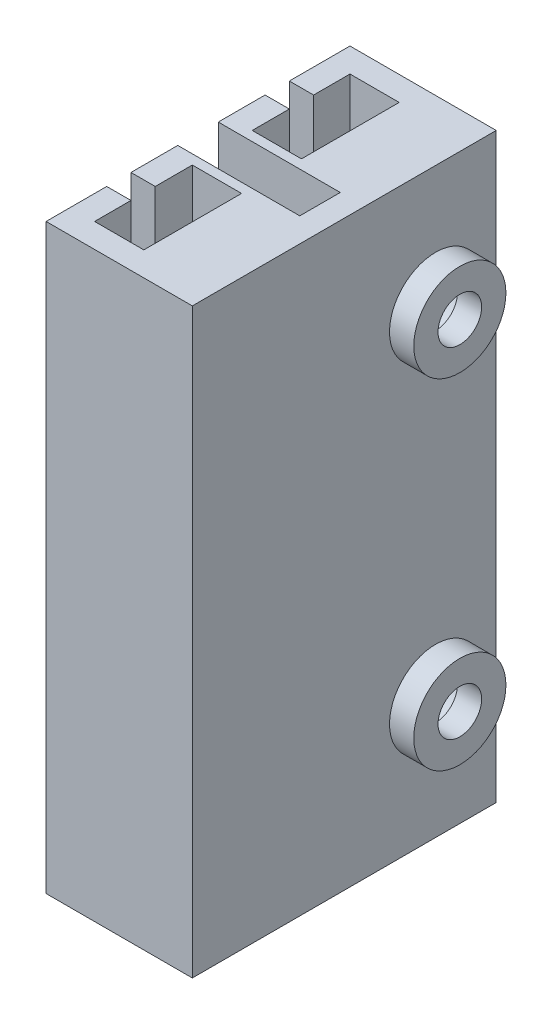
from build123d import *

# Parameters (mm, degrees)
SKETCH1_W           = 2.03
SKETCH1_H           = 4.03
BOSS_EXTRUDE1_DEPTH = 24
SKETCH2_W           = 1
SKETCH2_H           = 24
CUT_EXTRUDE1_DEPTH  = 2
SKETCH3_R           = 1.9
SKETCH3_R_2         = 0.9
BOSS_EXTRUDE2_DEPTH = 1
SKETCH4_R           = 1.15
CUT_EXTRUDE2_DEPTH  = 4


with BuildPart() as part:
    # Sketch1 → Boss-Extrude1 (new body)
    with BuildSketch(Plane(origin=(0, 0, 0), x_dir=(1, 0, 0), z_dir=(0, 1, 0))):
        Polygon((0.758759529, 5.315), (5, 5.315), (5, -7.215), (1.398203198, -7.215), (-1.03, -7.215), (-1.03, -1.785), (4, -1.785), (4, -0.115), (-1.03, -0.115), (-1.03, 5.315), align=None)
        with Locations((0.985, 2.3)):
            Rectangle(SKETCH1_W, SKETCH1_H, mode=Mode.SUBTRACT)
        with Locations((0.985, -4.2)):
            Rectangle(SKETCH1_W, SKETCH1_H, mode=Mode.SUBTRACT)
    extrude(amount=BOSS_EXTRUDE1_DEPTH)

    # Sketch2 → Cut-Extrude1 (cut)
    with BuildSketch(Plane.ZY.offset(1.03)):
        with Locations((-2.315, 12)):
            Rectangle(SKETCH2_W, SKETCH2_H)
        with Locations((4.215, 12)):
            Rectangle(SKETCH2_W, SKETCH2_H)
    extrude(amount=-CUT_EXTRUDE1_DEPTH, mode=Mode.SUBTRACT)

    # Sketch3 → Boss-Extrude2 (add)
    with BuildSketch(Plane(origin=(5, 0, 0), x_dir=(0, 0, -1), z_dir=(1, 0, 0))):
        with Locations((2.815, 19)):
            Circle(SKETCH3_R)
        with Locations((2.815, 19)):
            Circle(SKETCH3_R_2, mode=Mode.SUBTRACT)
        with Locations((2.815, 5)):
            Circle(SKETCH3_R)
        with Locations((2.815, 5)):
            Circle(SKETCH3_R_2, mode=Mode.SUBTRACT)
    extrude(amount=BOSS_EXTRUDE2_DEPTH)

    # Sketch4 → Cut-Extrude2 (cut)
    with BuildSketch(Plane(origin=(5, 0, 0), x_dir=(0, 0, -1), z_dir=(1, 0, 0))):
        with Locations((2.815, 19)):
            Circle(SKETCH4_R)
        with Locations((2.815, 5)):
            Circle(SKETCH4_R)
    extrude(amount=-CUT_EXTRUDE2_DEPTH, mode=Mode.SUBTRACT)


solid = part.part
